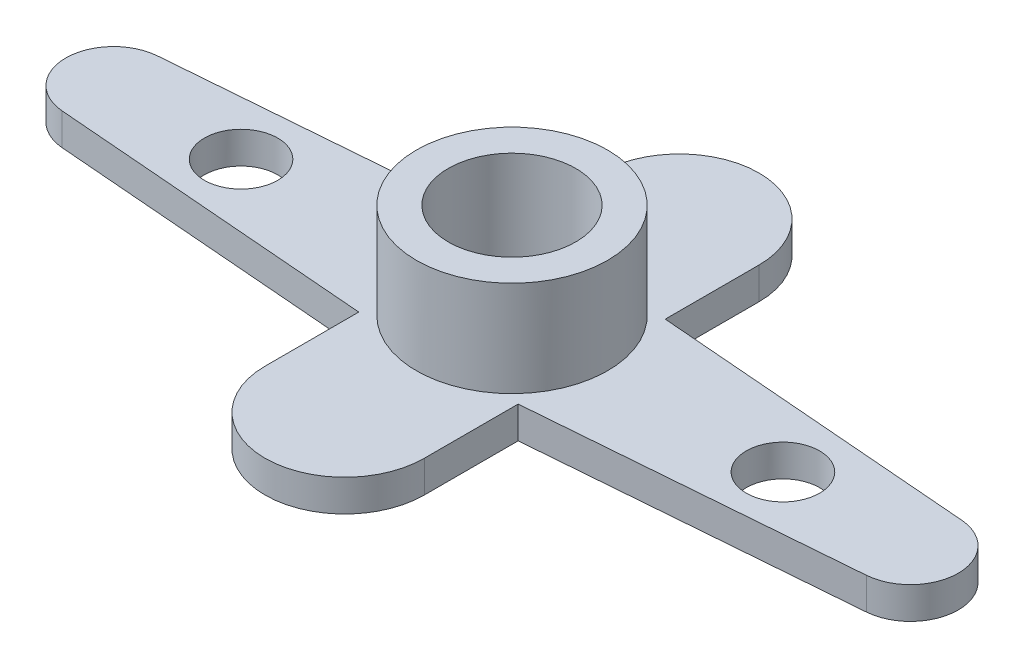
from build123d import *

# Parameters (mm, degrees)
SKICA1_R                 = 2
P_IDAT_VYSUNUT_M1_DEPTH  = 1
SKICA2_R                 = 1.15
ODEBRAT_VYSUNUT_M1_DEPTH = 2
SKICA3_R                 = 3
SKICA3_R_2               = 2
P_IDAT_VYSUNUT_M2_DEPTH  = 3


with BuildPart() as part:
    # Skica1 → Přidat vysunutím1 (new body)
    with BuildSketch(Plane(origin=(0, 0, 0), x_dir=(1, 0, 0), z_dir=(0, 1, 0))):
        with BuildLine():
            Line((-12.62, 1.495192295), (-2.5, 2.307395517))
            Line((-2.5, 2.307395517), (-2.5, 5.25))
            ThreePointArc((-2.5, 5.25), (0, 7.75), (2.5, 5.25))
            Line((2.5, 5.25), (2.5, 2.307395517))
            Line((2.5, 2.307395517), (12.62, 1.495192295))
            ThreePointArc((12.62, 1.495192295), (14, 0), (12.62, -1.495192295))
            Line((12.62, -1.495192295), (2.5, -2.307395517))
            Line((2.5, -2.307395517), (2.5, -5.25))
            ThreePointArc((2.5, -5.25), (0, -7.75), (-2.5, -5.25))
            Line((-2.5, -5.25), (-2.5, -2.307395517))
            Line((-2.5, -2.307395517), (-12.62, -1.495192295))
            ThreePointArc((-12.62, -1.495192295), (-14, 0), (-12.62, 1.495192295))
        make_face()
        Circle(SKICA1_R, mode=Mode.SUBTRACT)
    extrude(amount=P_IDAT_VYSUNUT_M1_DEPTH)

    # Skica2 → Odebrat vysunutím1 (cut)
    with BuildSketch(Plane(origin=(0, 1, 0), x_dir=(1, 0, 0), z_dir=(0, 1, 0))):
        with Locations((-8.5, 0)):
            Circle(SKICA2_R)
        with Locations((8.5, 0)):
            Circle(SKICA2_R)
    extrude(amount=-ODEBRAT_VYSUNUT_M1_DEPTH, mode=Mode.SUBTRACT)

    # Skica3 → Přidat vysunutím2 (add)
    with BuildSketch(Plane(origin=(0, 1, 0), x_dir=(1, 0, 0), z_dir=(0, 1, 0))):
        Circle(SKICA3_R)
        Circle(SKICA3_R_2, mode=Mode.SUBTRACT)
    extrude(amount=P_IDAT_VYSUNUT_M2_DEPTH)


solid = part.part
